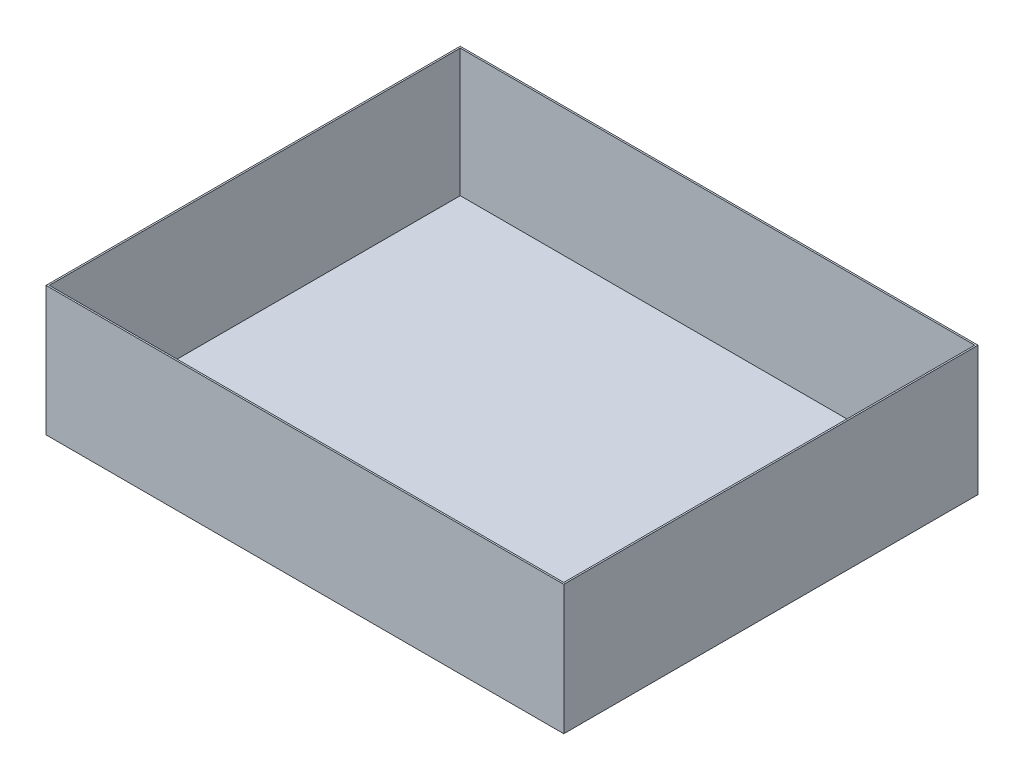
from build123d import *

# Parameters (mm, degrees)
SKETCH1_W           = 254
SKETCH1_H           = 203.2
BOSS_EXTRUDE1_DEPTH = 63.5
SHELL3_T            = -0.79375


with BuildPart() as part:
    # Sketch1 → Boss-Extrude1 (new body)
    with BuildSketch(Plane(origin=(0, 0, 0), x_dir=(1, 0, 0), z_dir=(0, 1, 0))):
        with Locations((127, 101.6)):
            Rectangle(SKETCH1_W, SKETCH1_H)
    extrude(amount=BOSS_EXTRUDE1_DEPTH)

    # Shell3
    shell3_openings = [part.faces().sort_by_distance(p)[0] for p in [
        (127, 63.5, -101.6),
    ]]
    offset(amount=SHELL3_T, openings=shell3_openings, kind=Kind.INTERSECTION)


solid = part.part
